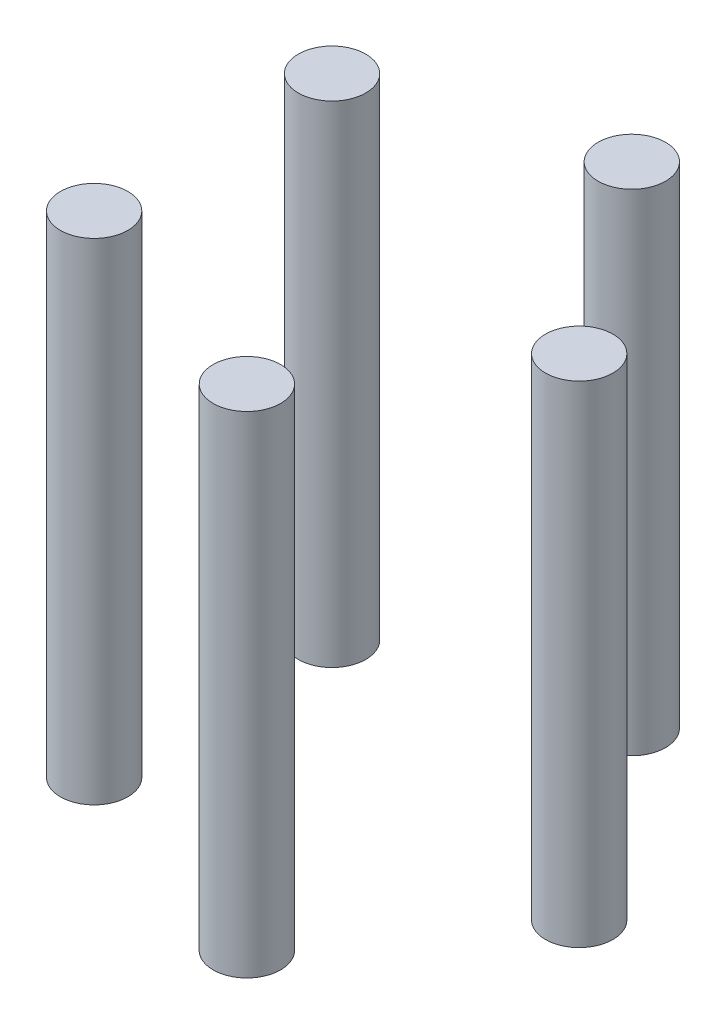
from build123d import *

# Parameters (mm, degrees)
SKETCH1_R             = 5.5
BOSS_EXTRUDE1_DEPTH   = 80
BOSS_EXTRUDE1_2_DEPTH = 80
BOSS_EXTRUDE1_3_DEPTH = 80
BOSS_EXTRUDE1_4_DEPTH = 80
BOSS_EXTRUDE1_5_DEPTH = 80


with BuildPart() as part:
    # Sketch1 → Boss-Extrude1 (new body)
    with BuildSketch(Plane(origin=(0, 0, 0), x_dir=(1, 0, 0), z_dir=(0, 1, 0))):
        with Locations((33, 0)):
            Circle(SKETCH1_R)
    extrude(amount=BOSS_EXTRUDE1_DEPTH)


with BuildPart() as body_2:
    # Sketch1 → Boss-Extrude1 2 (new body)
    with BuildSketch(Plane(origin=(0, 0, 0), x_dir=(1, 0, 0), z_dir=(0, 1, 0))):
        with Locations((10.197560814, -31.384865038)):
            Circle(SKETCH1_R)
    extrude(amount=BOSS_EXTRUDE1_2_DEPTH)


with BuildPart() as body_3:
    # Sketch1 → Boss-Extrude1 3 (new body)
    with BuildSketch(Plane(origin=(0, 0, 0), x_dir=(1, 0, 0), z_dir=(0, 1, 0))):
        with Locations((-26.697560814, -19.396913326)):
            Circle(SKETCH1_R)
    extrude(amount=BOSS_EXTRUDE1_3_DEPTH)


with BuildPart() as body_4:
    # Sketch1 → Boss-Extrude1 4 (new body)
    with BuildSketch(Plane(origin=(0, 0, 0), x_dir=(1, 0, 0), z_dir=(0, 1, 0))):
        with Locations((-26.697560814, 19.396913326)):
            Circle(SKETCH1_R)
    extrude(amount=BOSS_EXTRUDE1_4_DEPTH)


with BuildPart() as body_5:
    # Sketch1 → Boss-Extrude1 5 (new body)
    with BuildSketch(Plane(origin=(0, 0, 0), x_dir=(1, 0, 0), z_dir=(0, 1, 0))):
        with Locations((10.197560814, 31.384865038)):
            Circle(SKETCH1_R)
    extrude(amount=BOSS_EXTRUDE1_5_DEPTH)


solid = Compound([part.part, body_2.part, body_3.part, body_4.part, body_5.part])
